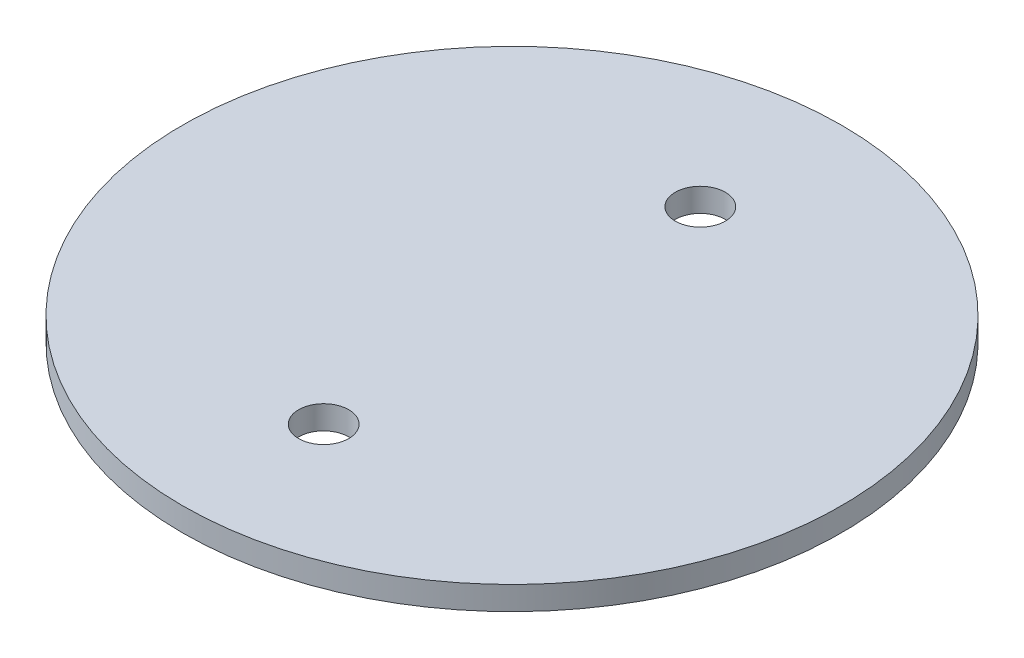
from build123d import *

# Parameters (mm, degrees)
SKETCH1_R               = 44.45
BOSS_EXTRUDE1_DEPTH     = 1.5875
F_1_4_CLEARANCE_HOLE1_D = 6.7564


with BuildPart() as part:
    # Sketch1 → Boss-Extrude1 (new body, symmetric)
    with BuildSketch(Plane(origin=(0, 0, 0), x_dir=(1, 0, 0), z_dir=(0, 1, 0))):
        Circle(SKETCH1_R)
    extrude(amount=BOSS_EXTRUDE1_DEPTH, both=True)

    # 1/4 Clearance Hole1 (through all)
    with Locations(Plane(origin=(0, 1.5875, 0), x_dir=(1, 0, 0), z_dir=(0, 1, 0))):
        with Locations((0, 25.4), (0, -25.4)):
            Hole(F_1_4_CLEARANCE_HOLE1_D / 2)


solid = part.part
